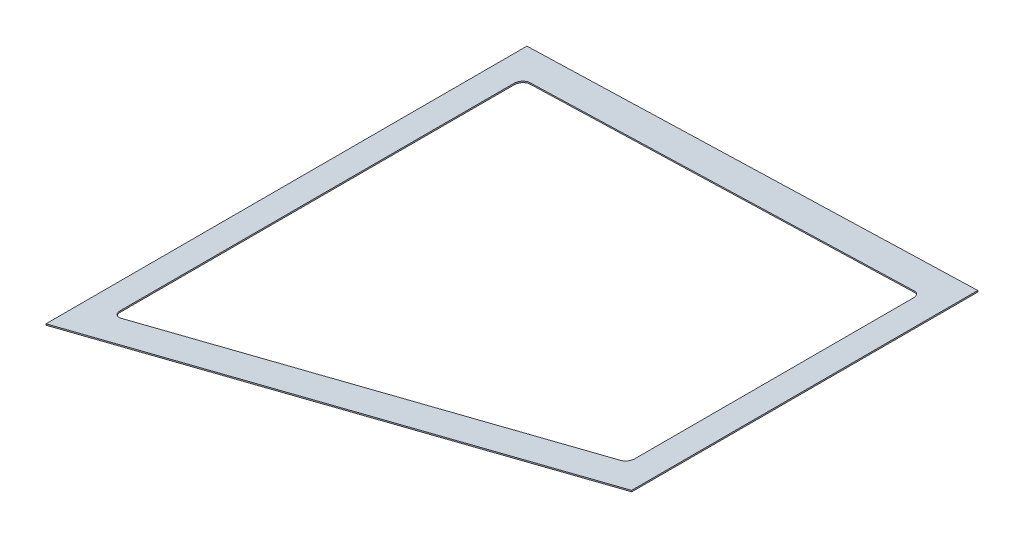
from build123d import *

# Parameters (mm, degrees)
BOSS_EXTRUDE1_DEPTH = 1


with BuildPart() as part:
    # Sketch1 → Boss-Extrude1 (new body)
    with BuildSketch(Plane(origin=(40.721862841, -259.93142883, 0), x_dir=(0.987949588, 0.154776003, 0), z_dir=(0.154776003, -0.987949588, 0))):
        Polygon((2498.917023581, -58.444774641), (2498.917023581, -139.900786314), (2074.988000168, -194.317166252), (2074.988000168, 194.317166252), (2498.917023581, 139.900786314), (2498.917023581, 58.444774641), align=None)
        with BuildLine():
            Line((2473.917023581, -58.444774641), (2473.917023581, -112.625661461))
            ThreePointArc((2473.917023581, -112.625661461), (2472.421655996, -116.589029575), (2468.680927979, -118.57683362))
            Line((2468.680927979, -118.57683362), (2106.751904566, -165.034769173))
            ThreePointArc((2106.751904566, -165.034769173), (2102.024632054, -163.588229428), (2099.988000168, -159.083597013))
            Line((2099.988000168, -159.083597013), (2099.988000168, 159.083597013))
            ThreePointArc((2099.988000168, 159.083597013), (2102.024632054, 163.588229428), (2106.751904566, 165.034769173))
            Line((2106.751904566, 165.034769173), (2468.680927979, 118.57683362))
            ThreePointArc((2468.680927979, 118.57683362), (2472.421655996, 116.589029575), (2473.917023581, 112.625661461))
            Line((2473.917023581, 112.625661461), (2473.917023581, 58.444774641))
            Line((2473.917023581, 58.444774641), (2473.917023581, -58.444774641))
        make_face(mode=Mode.SUBTRACT)
    extrude(amount=BOSS_EXTRUDE1_DEPTH)


solid = part.part
